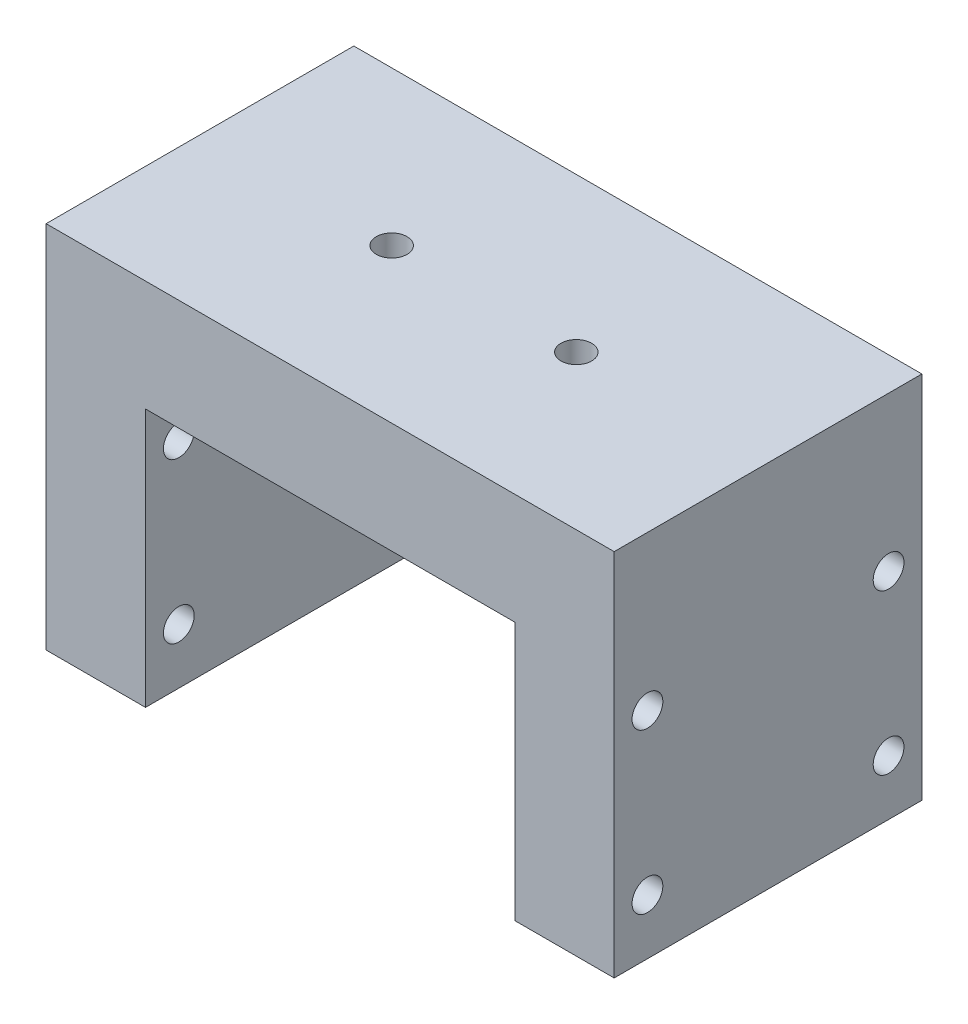
from build123d import *

# Parameters (mm, degrees)
BOSS_EXTRUDE1_DEPTH       = 12.5
M3X0_5_TAPPED_HOLE1_D     = 2.5
M3X0_5_TAPPED_HOLE1_DEPTH = 8
M3X0_5_TAPPED_HOLE1_TIP   = 0.751075774
F_2_5MM_DOWEL_HOLE1_D     = 2.5


with BuildPart() as part:
    # Sketch2 → Boss-Extrude1 (new body, symmetric)
    with BuildSketch(Plane.XY):
        Polygon((-23.075, -21), (-23.075, 9), (23.075, 9), (23.075, -21), (15, -21), (15, 0), (-15, 0), (-15, -21), align=None)
    extrude(amount=BOSS_EXTRUDE1_DEPTH, both=True)

    # M3x0.5 Tapped Hole1
    with Locations(Plane(origin=(0, 9, 0), x_dir=(1, 0, 0), z_dir=(0, 1, 0))):
        with Locations((-7.5, 0), (7.5, 0)):
            Hole(M3X0_5_TAPPED_HOLE1_D / 2, depth=M3X0_5_TAPPED_HOLE1_DEPTH)
            with Locations((0, 0, -(M3X0_5_TAPPED_HOLE1_DEPTH + M3X0_5_TAPPED_HOLE1_TIP / 2))):  # 118° drill point
                Cone(0, M3X0_5_TAPPED_HOLE1_D / 2, M3X0_5_TAPPED_HOLE1_TIP, mode=Mode.SUBTRACT)

    # Ø2.5mm Dowel Hole1 (through all)
    with Locations(Plane.ZY.offset(23.075)):
        with Locations((-9.795, -3.53), (9.795, -16.5), (-9.795, -16.5), (9.795, -3.53)):
            Hole(F_2_5MM_DOWEL_HOLE1_D / 2)


solid = part.part
